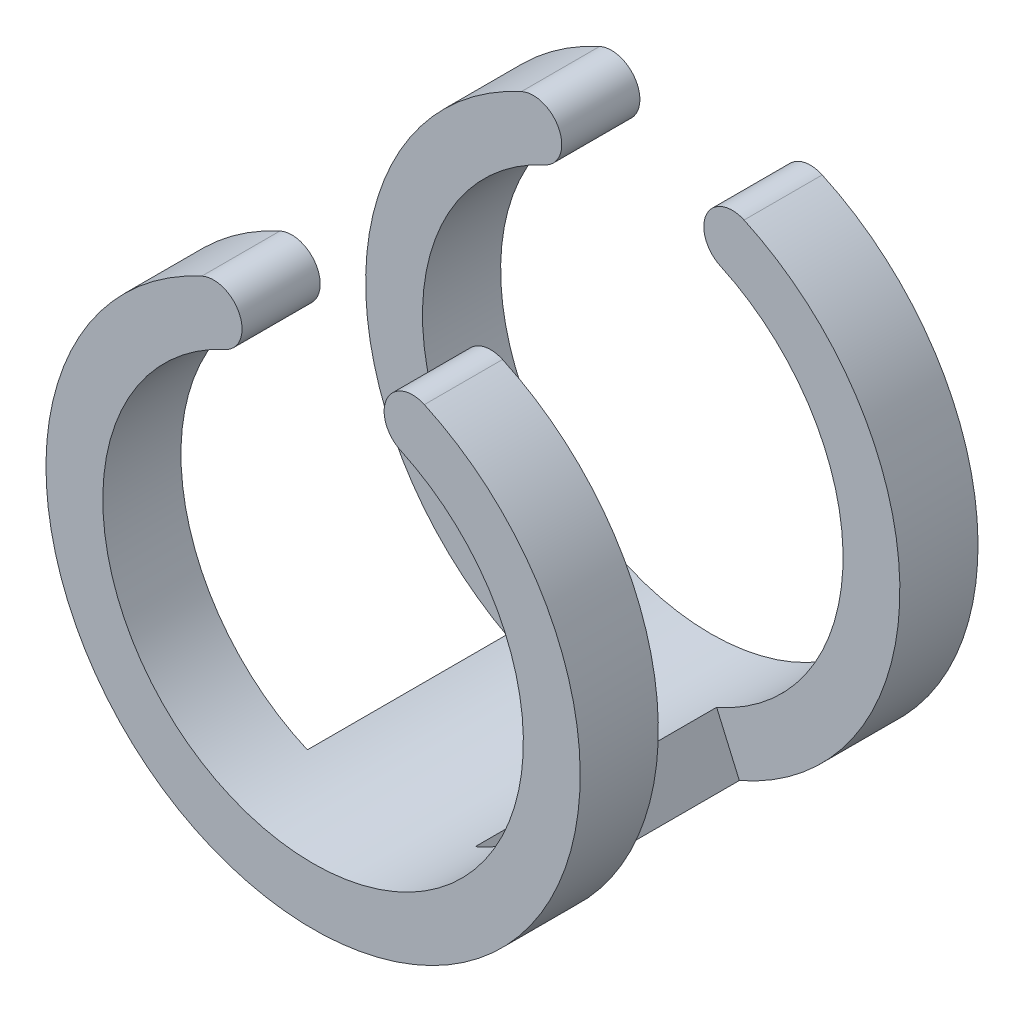
from build123d import *

# Parameters (mm, degrees)
EXTRUDE_1_DEPTH     = 7
CUT_EXTRUDE_1_DEPTH = 4.25


with BuildPart() as part:
    # 草图1 → 凸台-拉伸1 (new body, symmetric)
    with BuildSketch(Plane.XY):
        with BuildLine():
            ThreePointArc((-3.083333333, 6.727039137), (0, -7.4), (3.083333333, 6.727039137))
            ThreePointArc((3.083333333, 6.727039137), (2.590940657, 8.052765147), (3.916666667, 8.545157823))
            ThreePointArc((3.916666667, 8.545157823), (0, -9.4), (-3.916666667, 8.545157823))
            ThreePointArc((-3.916666667, 8.545157823), (-2.590940657, 8.052765147), (-3.083333333, 6.727039137))
        make_face()
    extrude(amount=EXTRUDE_1_DEPTH, both=True)

    # 草图2 → 切除-拉伸1 (cut, symmetric)
    with BuildSketch(Plane.XY):
        with BuildLine():
            Line((-2.95212766, -6.785642363), (-3.75, -8.619599759))
            ThreePointArc((-3.75, -8.619599759), (-9.399556913, -0.091267984), (-3.916666667, 8.545157823))
            ThreePointArc((-3.916666667, 8.545157823), (-2.590940657, 8.052765147), (-3.083333333, 6.727039137))
            ThreePointArc((-3.083333333, 6.727039137), (-7.399651187, -0.071849264), (-2.95212766, -6.785642363))
        make_face()
        with BuildLine():
            Line((2.95212766, -6.785642363), (3.75, -8.619599759))
            ThreePointArc((3.75, -8.619599759), (9.399556913, -0.091267984), (3.916666667, 8.545157823))
            ThreePointArc((3.916666667, 8.545157823), (2.590940657, 8.052765147), (3.083333333, 6.727039137))
            ThreePointArc((3.083333333, 6.727039137), (7.399651187, -0.071849264), (2.95212766, -6.785642363))
        make_face()
    extrude(amount=CUT_EXTRUDE_1_DEPTH, both=True, mode=Mode.SUBTRACT)


solid = part.part
